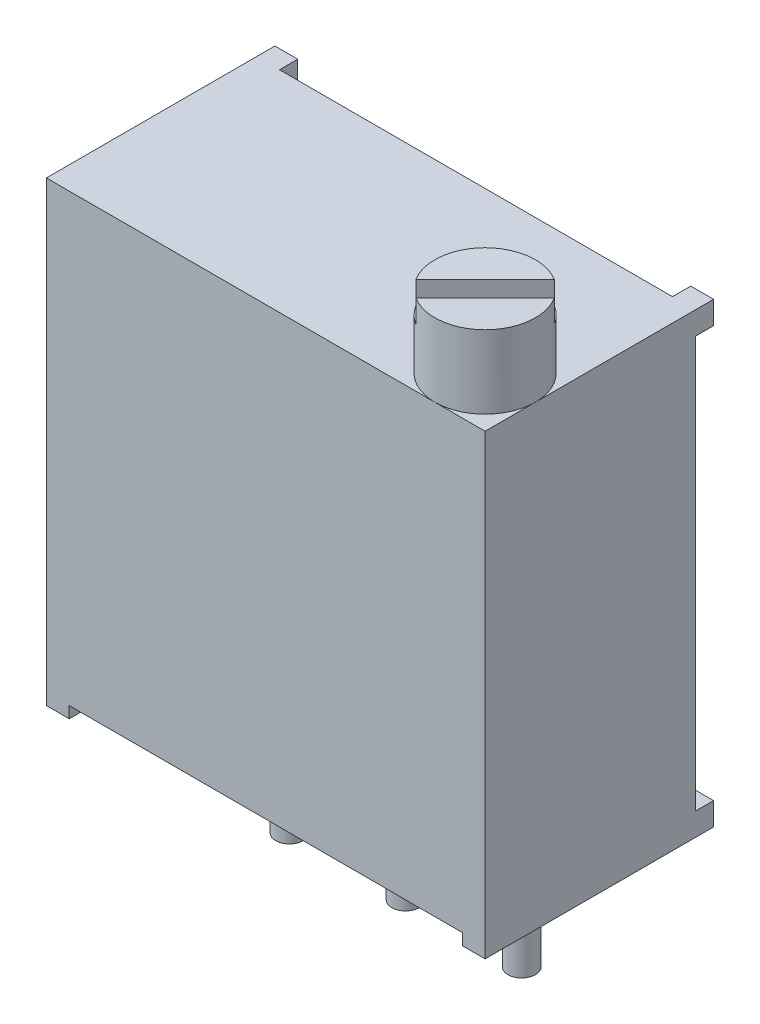
from build123d import *

# Parameters (mm, degrees)
COMPONENT_OUTLINE_W = 9.6
COMPONENT_OUTLINE_H = 5
BOSS_EXTRUDE1_DEPTH = 10
SKETCH1_OUTSIDE_W   = 14.548
SKETCH1_OUTSIDE_H   = 14.948
SKETCH1_OUTSIDE_W_2 = 0.5
SKETCH1_OUTSIDE_H_2 = 0.5
CUT_EXTRUDE1_DEPTH  = 0.4
SKETCH2_W           = 8.6
SKETCH2_H           = 4.6
CUT_EXTRUDE2_DEPTH  = 0.25
SKETCH3_R           = 0.3
BOSS_EXTRUDE2_DEPTH = 3
SKETCH4_R           = 1.1
BOSS_EXTRUDE3_DEPTH = 1.6
CUT_EXTRUDE3_DEPTH  = 0.5


with BuildPart() as part:
    # Component_Outline → Boss-Extrude1 (new body)
    with BuildSketch(Plane(origin=(0, 0, 0), x_dir=(1, 0, 0), z_dir=(0, 1, 0))):
        with Locations((-2.6, -0.5)):
            Rectangle(COMPONENT_OUTLINE_W, COMPONENT_OUTLINE_H)
    extrude(amount=BOSS_EXTRUDE1_DEPTH)

    # Sketch1 outside → Cut-Extrude1 (cut)
    with BuildSketch(Plane(origin=(0, 0, -2), x_dir=(-1, 0, 0), z_dir=(0, 0, -1))):
        with Locations((2.6, 5)):
            Rectangle(SKETCH1_OUTSIDE_W, SKETCH1_OUTSIDE_H)
        with Locations((7.15, 9.75)):
            Rectangle(SKETCH1_OUTSIDE_W_2, SKETCH1_OUTSIDE_H_2, mode=Mode.SUBTRACT)
        with Locations((-1.95, 9.75)):
            Rectangle(SKETCH1_OUTSIDE_W_2, SKETCH1_OUTSIDE_H_2, mode=Mode.SUBTRACT)
        with Locations((-1.95, 0.25)):
            Rectangle(SKETCH1_OUTSIDE_W_2, SKETCH1_OUTSIDE_H_2, mode=Mode.SUBTRACT)
        with Locations((7.15, 0.25)):
            Rectangle(SKETCH1_OUTSIDE_W_2, SKETCH1_OUTSIDE_H_2, mode=Mode.SUBTRACT)
    extrude(amount=-CUT_EXTRUDE1_DEPTH, mode=Mode.SUBTRACT)

    # Sketch2 → Cut-Extrude2 (cut)
    with BuildSketch(Plane.XZ):
        with Locations((-2.6, 0.7)):
            Rectangle(SKETCH2_W, SKETCH2_H)
    extrude(amount=-CUT_EXTRUDE2_DEPTH, mode=Mode.SUBTRACT)

    # Sketch3 → Boss-Extrude2 (add)
    with BuildSketch(Plane.XZ.offset(-0.25)):
        Circle(SKETCH3_R)
        with Locations((-2.54, 0)):
            Circle(SKETCH3_R)
        with Locations((-5.08, 0)):
            Circle(SKETCH3_R)
    extrude(amount=BOSS_EXTRUDE2_DEPTH)


with BuildPart() as body_2:
    # Sketch4 → Boss-Extrude3 (new body)
    with BuildSketch(Plane(origin=(0, 10, 0), x_dir=(1, 0, 0), z_dir=(0, 1, 0))):
        with Locations((1.1, -1.9)):
            Circle(SKETCH4_R)
    extrude(amount=BOSS_EXTRUDE3_DEPTH)

    # Sketch5 → Cut-Extrude3 (cut)
    with BuildSketch(Plane(origin=(0, 11.6, 0), x_dir=(1, 0, 0), z_dir=(0, 1, 0))):
        with BuildLine():
            Line((0.165760434, -2.480686175), (1.680686175, -0.965760434))
            ThreePointArc((1.680686175, -0.965760434), (1.877817459, -1.122182541), (2.034239566, -1.319313825))
            Line((2.034239566, -1.319313825), (0.519313825, -2.834239566))
            ThreePointArc((0.519313825, -2.834239566), (0.322182541, -2.677817459), (0.165760434, -2.480686175))
        make_face()
    extrude(amount=-CUT_EXTRUDE3_DEPTH, mode=Mode.SUBTRACT)


solid = Compound([part.part, body_2.part])
